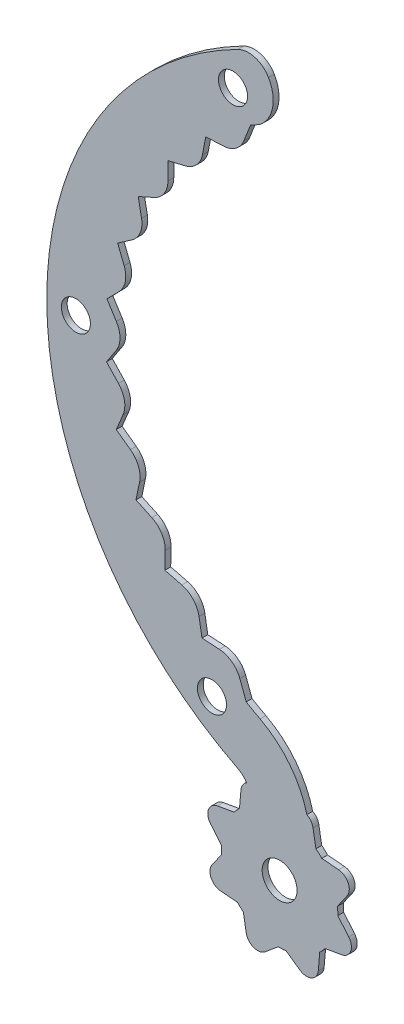
from build123d import *

# Parameters (mm, degrees)
IZIM1_R                     = 5
IZIM1_R_2                   = 2.5
Y_KSEKLIK_EKSTR_ZYON2_DEPTH = 1
IZIM2_R                     = 3
Y_KSEKLIK_EKSTR_ZYON4_DEPTH = 1


with BuildPart() as part:
    # Çizim1 → Yükseklik-Ekstrüzyon2 (new body)
    with BuildSketch(Plane.XY):
        with BuildLine():
            Line((-25, 43.301270189), (-26.146521576, 40.39207739))
            ThreePointArc((-26.146521576, 40.39207739), (-27.544598222, 38.602623821), (-29.691484877, 37.862596744))
            Line((-29.691484877, 37.862596744), (-32.693673826, 37.730024144))
            Line((-32.693673826, 37.730024144), (-33.252115355, 34.777253066))
            ThreePointArc((-33.252115355, 34.777253066), (-34.290118058, 32.757522199), (-36.260310201, 31.628316593))
            Line((-36.260310201, 31.628316593), (-39.184480502, 30.935538106))
            Line((-39.184480502, 30.935538106), (-39.17973637, 27.930427214))
            ThreePointArc((-39.17973637, 27.930427214), (-39.820893366, 25.751969023), (-41.54459596, 24.273587558))
            Line((-41.54459596, 24.273587558), (-44.287157421, 23.045145208))
            Line((-44.287157421, 23.045145208), (-43.719395692, 20.094152054))
            ThreePointArc((-43.719395692, 20.094152054), (-43.940993675, 17.834139505), (-45.357143694, 16.058954583))
            Line((-45.357143694, 16.058954583), (-47.82093971, 14.338366552))
            Line((-47.82093971, 14.338366552), (-46.710273625, 11.546031539))
            ThreePointArc((-46.710273625, 11.546031539), (-46.504462376, 9.284526705), (-47.562892001, 7.275425136))
            Line((-47.562892001, 7.275425136), (-49.660641368, 5.123644113))
            Line((-49.660641368, 5.123644113), (-48.046416828, 2.588887101))
            ThreePointArc((-48.046416828, 2.588887101), (-47.420487313, 0.406004917), (-48.083701146, -1.765839874))
            Line((-48.083701146, -1.765839874), (-49.741090048, -4.272585973))
            Line((-49.741090048, -4.272585973), (-47.680491761, -6.459969953))
            ThreePointArc((-47.680491761, -6.459969953), (-46.656617846, -8.486899797), (-46.901121207, -10.744549126))
            Line((-46.901121207, -10.744549126), (-48.059435816, -13.517457571))
            Line((-48.059435816, -13.517457571), (-45.625461503, -15.279979352))
            ThreePointArc((-45.625461503, -15.279979352), (-44.239914432, -17.079151855), (-44.057045667, -19.342627369))
            Line((-44.057045667, -19.342627369), (-44.675252109, -22.283466496))
            Line((-44.675252109, -22.283466496), (-41.954126526, -23.558687864))
            ThreePointArc((-41.954126526, -23.558687864), (-40.255989993, -25.066366444), (-39.652227319, -27.255483394))
            Line((-39.652227319, -27.255483394), (-39.708425324, -30.260072511))
            Line((-39.708425324, -30.260072511), (-36.7965457, -31.002818113))
            ThreePointArc((-36.7965457, -31.002818113), (-34.84597704, -32.165592505), (-33.842709051, -34.202800331))
            Line((-33.842709051, -34.202800331), (-33.334907776, -37.164700371))
            Line((-33.334907776, -37.164700371), (-30.335428898, -37.348658075))
            ThreePointArc((-30.335428898, -37.348658075), (-28.201527977, -38.125336415), (-26.834295942, -39.938466016))
            Line((-26.834295942, -39.938466016), (-25.73775467, -42.866863479))
            ThreePointArc((-25.73775467, -42.866863479), (-24.554196145, -43.55561332), (-23.352220135, -44.21169319))
            ThreePointArc((-23.352220135, -44.21169319), (-17.219408632, -49.939828574), (-14.829333353, -57.984109281))
            ThreePointArc((-14.829333353, -57.984109281), (-20.099106379, -76.543069457), (-25, -57.883306535))
            Line((-25, -57.883306535), (-25, -57.052607302))
            ThreePointArc((-25, -57.052607302), (-25.590454576, -54.960957236), (-27.1875, -53.486819346))
            ThreePointArc((-27.1875, -53.486819346), (-59.999999835, 0.004450967), (-27.179564099, 53.490852446))
            ThreePointArc((-27.179564099, 53.490852446), (-24.232021318, 53.76021953), (-21.906244367, 51.929556087))
            ThreePointArc((-21.906244367, 51.929556087), (-21.212806241, 47.755648425), (-23.446136356, 44.161959762))
            ThreePointArc((-23.446136356, 44.161959762), (-24.226890609, 43.73851588), (-25, 43.301270189))
        make_face()
        with Locations((-20, -66.543560573)):
            Circle(IZIM1_R, mode=Mode.SUBTRACT)
        with Locations((-31.620079453, -45.001895242)):
            Circle(IZIM1_R_2, mode=Mode.SUBTRACT)
        with Locations((-55, 0)):
            Circle(IZIM1_R_2, mode=Mode.SUBTRACT)
        with Locations((-28.000624989, 47.338831842)):
            Circle(IZIM1_R_2, mode=Mode.SUBTRACT)
    extrude(amount=Y_KSEKLIK_EKSTR_ZYON2_DEPTH)

    # Çizim2 → Yükseklik-Ekstrüzyon4 (add)
    with BuildSketch(Plane.XY.offset(1)):
        with BuildLine():
            Line((-14.268162917, -55.859645389), (-13.746523784, -58.818007922))
            ThreePointArc((-13.746523784, -58.818007922), (-13.437306239, -59.381637082), (-12.848871774, -59.640554443))
            Line((-12.848871774, -59.640554443), (-9.856302857, -59.902370298))
            ThreePointArc((-9.856302857, -59.902370298), (-8.217998769, -61.049523171), (-8.392310254, -63.041912567))
            Line((-8.392310254, -63.041912567), (-10.115333894, -65.502645344))
            ThreePointArc((-10.115333894, -65.502645344), (-10.295230071, -66.119841167), (-10.062226293, -66.71900939))
            Line((-10.062226293, -66.71900939), (-8.131292285, -69.02020693))
            ThreePointArc((-8.131292285, -69.02020693), (-7.78399593, -70.989822436), (-9.316084816, -72.275397656))
            Line((-9.316084816, -72.275397656), (-12.274447349, -72.797036789))
            ThreePointArc((-12.274447349, -72.797036789), (-12.838076508, -73.106254334), (-13.09699387, -73.694688799))
            Line((-13.09699387, -73.694688799), (-13.358809725, -76.687257716))
            ThreePointArc((-13.358809725, -76.687257716), (-14.505962597, -78.325561805), (-16.498351994, -78.151250319))
            Line((-16.498351994, -78.151250319), (-18.95908477, -76.428226679))
            ThreePointArc((-18.95908477, -76.428226679), (-19.576280594, -76.248330502), (-20.175448817, -76.48133428))
            Line((-20.175448817, -76.48133428), (-22.476646357, -78.412268288))
            ThreePointArc((-22.476646357, -78.412268288), (-24.446261863, -78.759564643), (-25.731837083, -77.227475757))
            Line((-25.731837083, -77.227475757), (-26.253476216, -74.269113224))
            ThreePointArc((-26.253476216, -74.269113224), (-26.562693761, -73.705484065), (-27.151128226, -73.446566704))
            Line((-27.151128226, -73.446566704), (-30.143697143, -73.184750849))
            ThreePointArc((-30.143697143, -73.184750849), (-31.782001231, -72.037597976), (-31.607689746, -70.04520858))
            Line((-31.607689746, -70.04520858), (-29.884666106, -67.584475803))
            ThreePointArc((-29.884666106, -67.584475803), (-29.704769929, -66.967279979), (-29.937773707, -66.368111757))
            Line((-29.937773707, -66.368111757), (-31.868707715, -64.066914216))
            ThreePointArc((-31.868707715, -64.066914216), (-32.21600407, -62.09729871), (-30.683915184, -60.811723491))
            Line((-30.683915184, -60.811723491), (-27.725552651, -60.290084357))
            ThreePointArc((-27.725552651, -60.290084357), (-27.161923492, -59.980866812), (-26.90300613, -59.392432347))
            Line((-26.90300613, -59.392432347), (-26.641190275, -56.39986343))
            ThreePointArc((-26.641190275, -56.39986343), (-25.494037403, -54.761559342), (-23.501648006, -54.935870827))
            Line((-23.501648006, -54.935870827), (-21.04091523, -56.658894467))
            ThreePointArc((-21.04091523, -56.658894467), (-20.423719406, -56.838790644), (-19.824551183, -56.605786866))
            Line((-19.824551183, -56.605786866), (-17.523353643, -54.674852858))
            ThreePointArc((-17.523353643, -54.674852858), (-15.553738137, -54.327556503), (-14.268162917, -55.859645389))
        make_face()
        with Locations((-20, -66.543560573)):
            Circle(IZIM2_R, mode=Mode.SUBTRACT)
    extrude(amount=-Y_KSEKLIK_EKSTR_ZYON4_DEPTH)


solid = part.part
